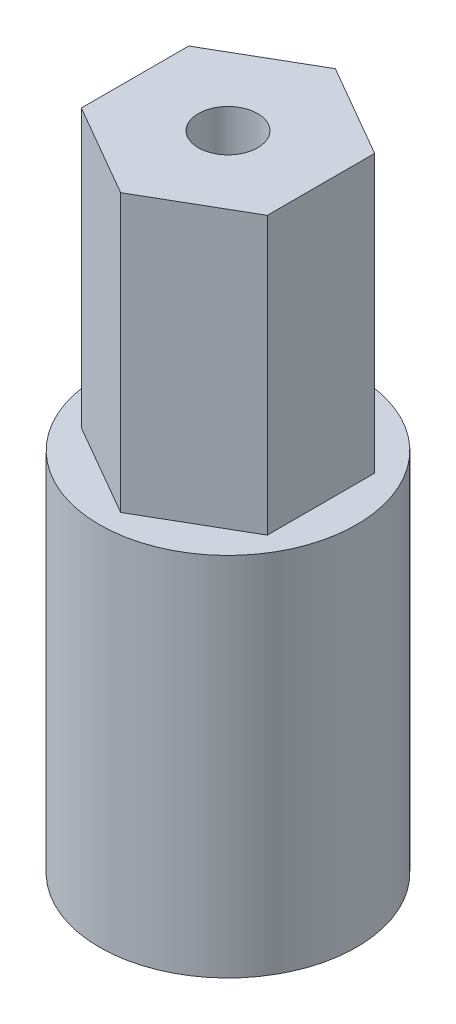
from build123d import *

# Parameters (mm, degrees)
SKETCH1_R           = 8.255
BOSS_EXTRUDE1_DEPTH = 23.495
SKETCH9_R           = 1.905
BOSS_EXTRUDE6_DEPTH = 17.78


with BuildPart() as part:
    # Sketch1 → Boss-Extrude1 (new body)
    with BuildSketch(Plane(origin=(0, 0, 0), x_dir=(1, 0, 0), z_dir=(0, 1, 0))):
        Circle(SKETCH1_R)
    extrude(amount=BOSS_EXTRUDE1_DEPTH)

    # Sketch9 → Boss-Extrude6 (add)
    with BuildSketch(Plane(origin=(0, 23.495, 0), x_dir=(1, 0, 0), z_dir=(0, 1, 0))):
        Polygon((0, 6.892407514), (-5.969, 3.446203757), (-5.969, -3.446203757), (0, -6.892407514), (5.969, -3.446203757), (5.969, 3.446203757), align=None)
        Circle(SKETCH9_R, mode=Mode.SUBTRACT)
    extrude(amount=BOSS_EXTRUDE6_DEPTH)


solid = part.part
